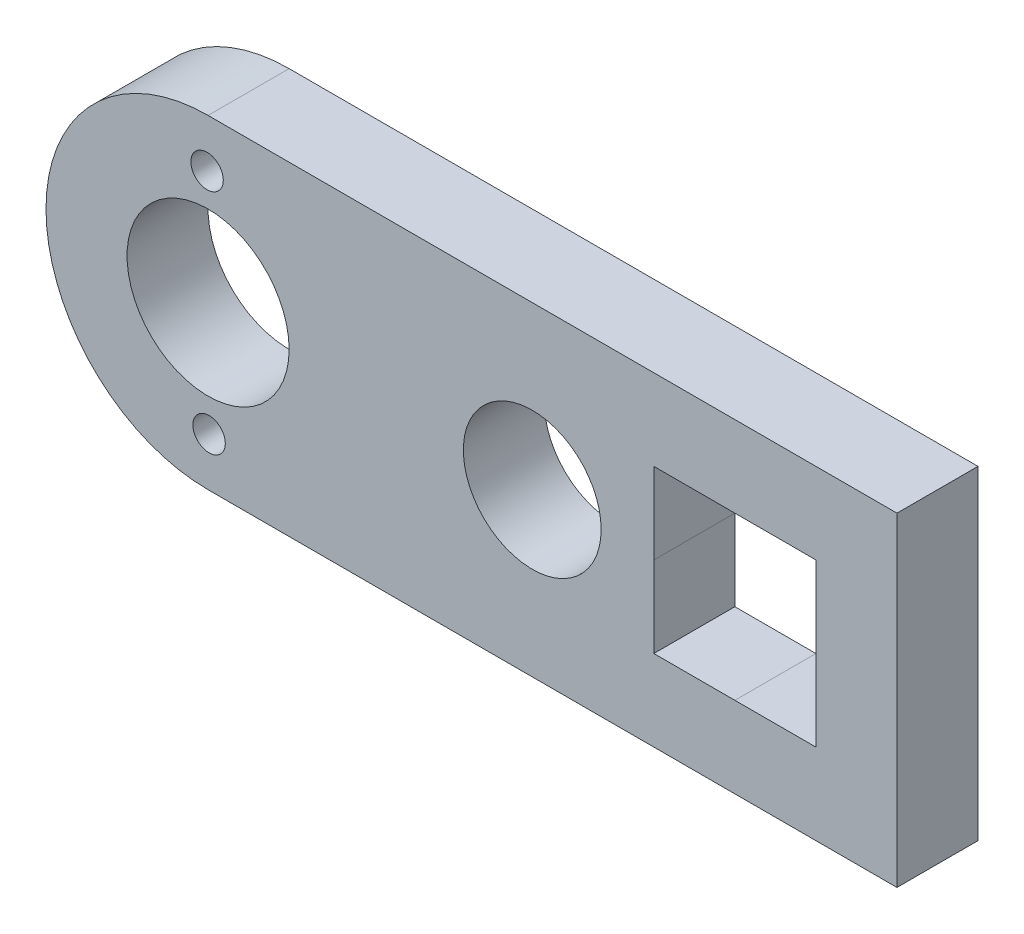
from build123d import *

# Parameters (mm, degrees)
SKETCH1_R           = 4.25
SKETCH1_R_2         = 5
SKETCH1_R_3         = 1
BOSS_EXTRUDE1_DEPTH = 5
SKETCH2_R           = 1
SKETCH2_R_2         = 1.224011965
BOSS_EXTRUDE2_DEPTH = 5


with BuildPart() as part:
    # Sketch1 → Boss-Extrude1 (new body)
    with BuildSketch(Plane.XY):
        with BuildLine():
            Line((0, 10), (42.5, 10))
            Line((42.5, 10), (42.5, -10))
            Line((42.5, -10), (0, -10))
            ThreePointArc((0, -10), (-10, 0), (0, 10))
        make_face()
        with Locations((20, 0)):
            Circle(SKETCH1_R, mode=Mode.SUBTRACT)
        Circle(SKETCH1_R_2, mode=Mode.SUBTRACT)
        with Locations((7, 0.062454575)):
            Circle(SKETCH1_R_3, mode=Mode.SUBTRACT)
        with Locations((0.062454575, -7)):
            Circle(SKETCH1_R_3, mode=Mode.SUBTRACT)
        with Locations((-7, -0.062454575)):
            Circle(SKETCH1_R_3, mode=Mode.SUBTRACT)
        with Locations((-0.062454575, 7)):
            Circle(SKETCH1_R_3, mode=Mode.SUBTRACT)
        Polygon((27.5, 5), (32.5, 5), (37.5, 5), (37.5, -5), (32.5, -5), (27.5, -5), (27.5, 0), align=None, mode=Mode.SUBTRACT)
    extrude(amount=BOSS_EXTRUDE1_DEPTH)

    # Sketch2 → Boss-Extrude2 (add)
    with BuildSketch(Plane(origin=(0, 0, 0), x_dir=(-1, 0, 0), z_dir=(0, 0, -1))):
        with Locations((7, -0.062454575)):
            Circle(SKETCH2_R)
        with Locations((-7, 0.062454575)):
            Circle(SKETCH2_R_2)
    extrude(amount=-BOSS_EXTRUDE2_DEPTH)


solid = part.part
